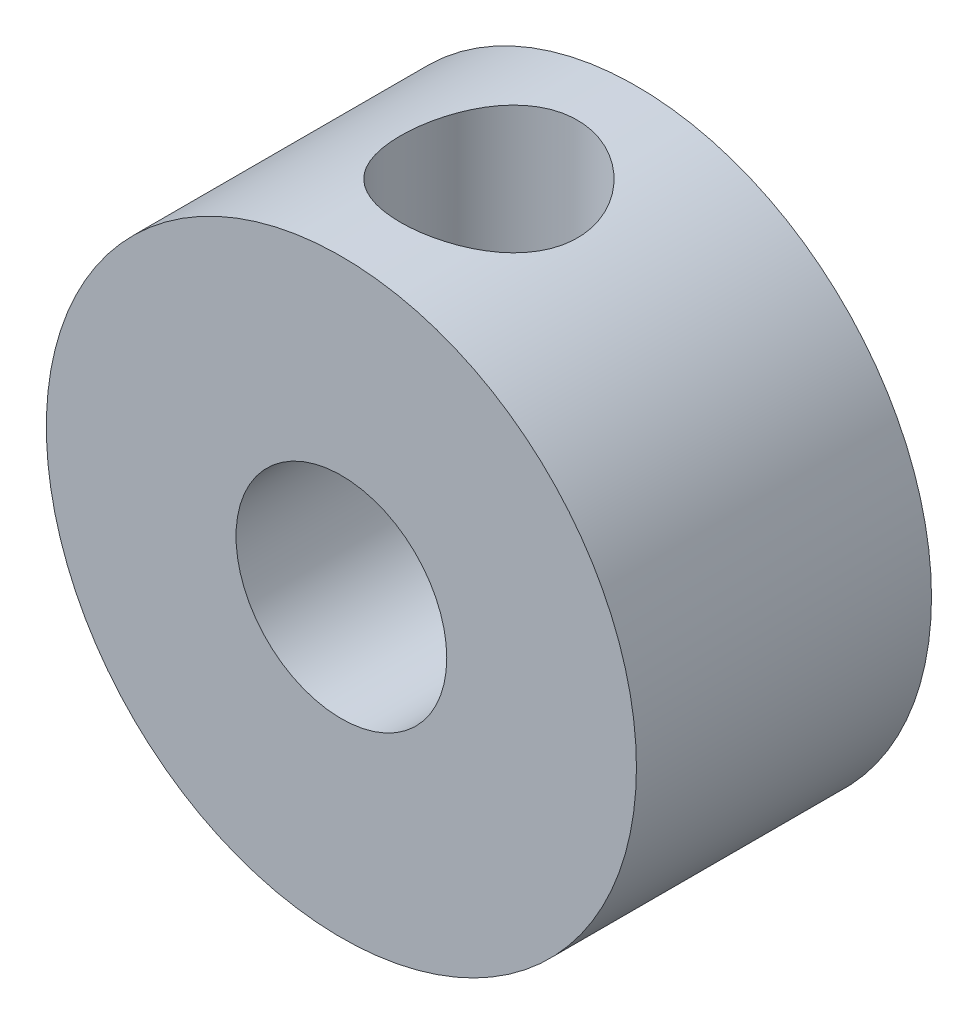
from build123d import *

# Parameters (mm, degrees)
SKETCH1_R                  = 7
SKETCH1_R_2                = 2.5
BOSS_EXTRUDE1_DEPTH        = 7
M5X0_8_TAPPED_HOLE1_REACH  = 19.146
M5X0_8_TAPPED_HOLE1_BORE_R = 2.1


with BuildPart() as part:
    # Sketch1 → Boss-Extrude1 (new body)
    with BuildSketch(Plane.XY):
        Circle(SKETCH1_R)
        Circle(SKETCH1_R_2, mode=Mode.SUBTRACT)
    extrude(amount=BOSS_EXTRUDE1_DEPTH)

    # M5x0.8 Tapped Hole1 bore → M5x0.8 Tapped Hole1 (cut, up to next)
    with BuildSketch(Plane(origin=(0, 7, 0), x_dir=(1, 0, 0), z_dir=(0, 1, 0)), mode=Mode.PRIVATE) as m5x0_8_tapped_hole1_sk1:
        with Locations((0, -3.5)):
            Circle(M5X0_8_TAPPED_HOLE1_BORE_R)
    m5x0_8_tapped_hole1_tool1 = extrude(m5x0_8_tapped_hole1_sk1.sketch, amount=-M5X0_8_TAPPED_HOLE1_REACH, mode=Mode.PRIVATE) & part.part
    add(m5x0_8_tapped_hole1_tool1.solids().sort_by_distance((0, 7, 3.5))[0], mode=Mode.SUBTRACT)


solid = part.part
